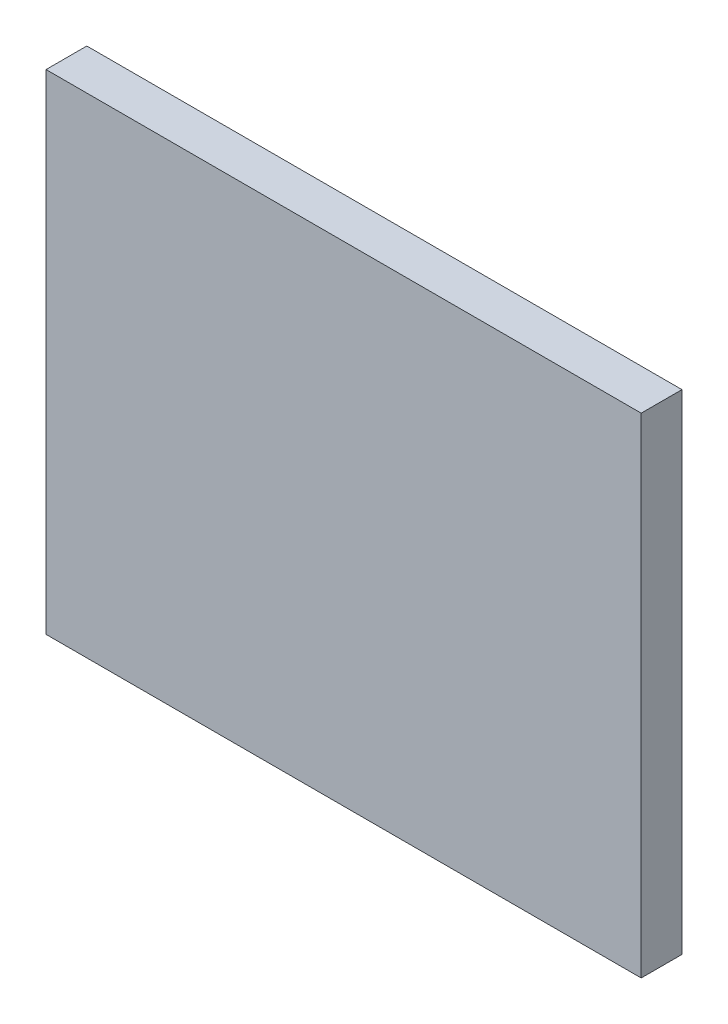
from build123d import *

# Parameters (mm, degrees)
ESQUISSE1_W        = 365
ESQUISSE1_H        = 300
BOSS_EXTRU_1_DEPTH = 25


with BuildPart() as part:
    # Esquisse1 → Boss.-Extru.1 (new body)
    with BuildSketch(Plane.XY):
        with Locations((-182.5, 150)):
            Rectangle(ESQUISSE1_W, ESQUISSE1_H)
    extrude(amount=BOSS_EXTRU_1_DEPTH)


solid = part.part
